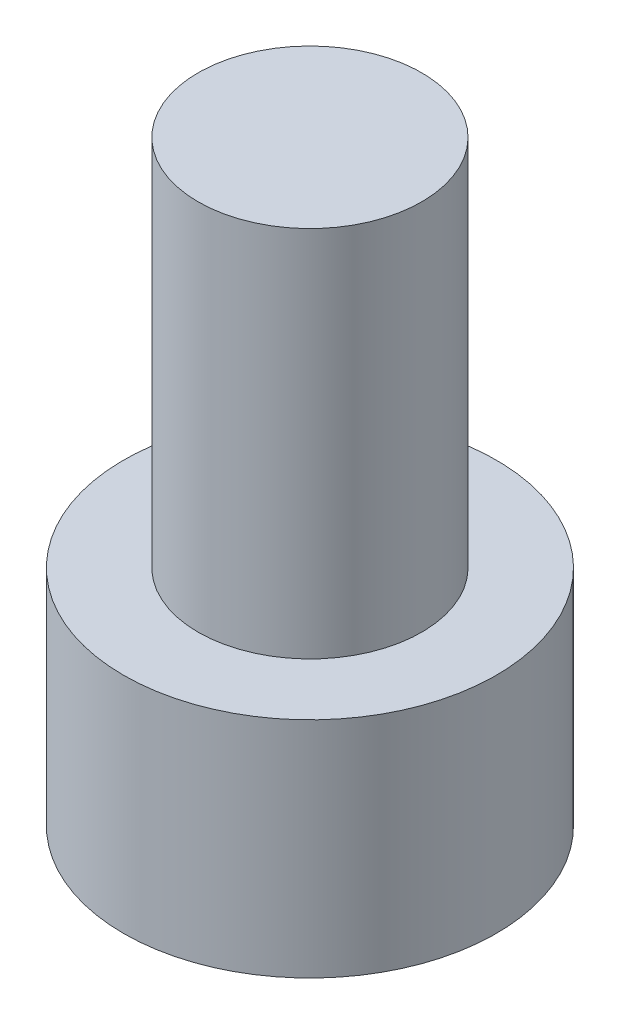
from build123d import *

# Parameters (mm, degrees)
SKETCH_1_R          = 2.5
EXTRUDE_1_DEPTH     = 3
SKETCH_2_R          = 1.5
EXTRUDE_2_DEPTH     = 5
CUT_EXTRUDE_1_DEPTH = 1.65


with BuildPart() as part:
    # 草图1 → 凸台-拉伸1 (new body)
    with BuildSketch(Plane(origin=(0, 0, 0), x_dir=(1, 0, 0), z_dir=(0, 1, 0))):
        Circle(SKETCH_1_R)
    extrude(amount=EXTRUDE_1_DEPTH)

    # 草图2 → 凸台-拉伸2 (add)
    with BuildSketch(Plane(origin=(0, 3, 0), x_dir=(1, 0, 0), z_dir=(0, 1, 0))):
        Circle(SKETCH_2_R)
    extrude(amount=EXTRUDE_2_DEPTH)

    # 草图3 → 切除-拉伸1 (cut)
    with BuildSketch(Plane.XZ):
        Polygon((1.425, 0), (0.7125, 1.2340862), (-0.7125, 1.2340862), (-1.425, 0), (-0.7125, -1.2340862), (0.7125, -1.2340862), align=None)
    extrude(amount=-CUT_EXTRUDE_1_DEPTH, mode=Mode.SUBTRACT)


solid = part.part
